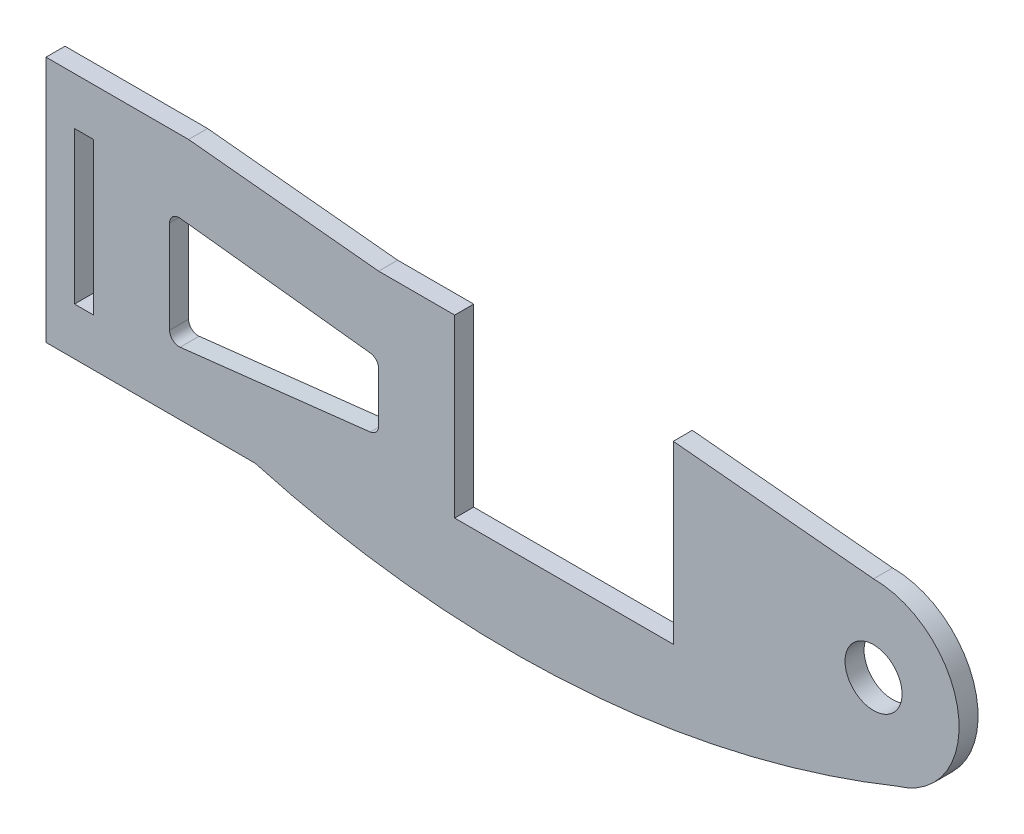
from build123d import *

# Parameters (mm, degrees)
ESBO_O1_R                = 3
ESBO_O1_W                = 2
ESBO_O1_H                = 16
RESSALTO_EXTRUS_O1_DEPTH = 2


with BuildPart() as part:
    # Esboço1 → Ressalto-extrusão1 (new body)
    with BuildSketch(Plane.XY):
        with BuildLine():
            Line((-21.07, 11), (0, 9))
            ThreePointArc((0, 9), (8.911247748, 1.260818614), (2.496770452, -8.646741427))
            add(Edge.make_bspline(
                [(-65.07, -13), (-43.239788601, -19.093527225), (-19.750123263, -17.642441034), (2.496770452, -8.646741427)],
                knots=[0, 0, 0, 0, 0.972962774, 0.972962774, 0.972962774, 0.972962774], degree=3))
            Line((-65.07, -13), (-87.07, -13))
            Line((-87.07, -13), (-87.07, 13))
            Line((-87.07, 13), (-72.07, 13))
            Line((-72.07, 13), (-52.07, 11))
            Line((-52.07, 11), (-44.07, 11))
            Line((-44.07, 11), (-44.07, -7.5))
            Line((-44.07, -7.5), (-21.07, -7.5))
            Line((-21.07, -7.5), (-21.07, 11))
        make_face()
        Circle(ESBO_O1_R, mode=Mode.SUBTRACT)
        with BuildLine():
            Line((-52.07, 2.107200462), (-52.07, -3.107200462))
            ThreePointArc((-52.07, -3.107200462), (-52.32404099, -3.773192321), (-52.957090312, -4.100805717))
            Line((-52.957090312, -4.100805717), (-72.957090312, -6.37353299))
            ThreePointArc((-72.957090312, -6.37353299), (-73.735991859, -6.125886745), (-74.07, -5.379927735))
            Line((-74.07, -5.379927735), (-74.07, 4.379927735))
            ThreePointArc((-74.07, 4.379927735), (-73.735991859, 5.125886745), (-72.957090312, 5.37353299))
            Line((-72.957090312, 5.37353299), (-52.957090312, 3.100805717))
            ThreePointArc((-52.957090312, 3.100805717), (-52.32404099, 2.773192321), (-52.07, 2.107200462))
        make_face(mode=Mode.SUBTRACT)
        with Locations((-83.07, 0)):
            Rectangle(ESBO_O1_W, ESBO_O1_H, mode=Mode.SUBTRACT)
    extrude(amount=RESSALTO_EXTRUS_O1_DEPTH)


solid = part.part
